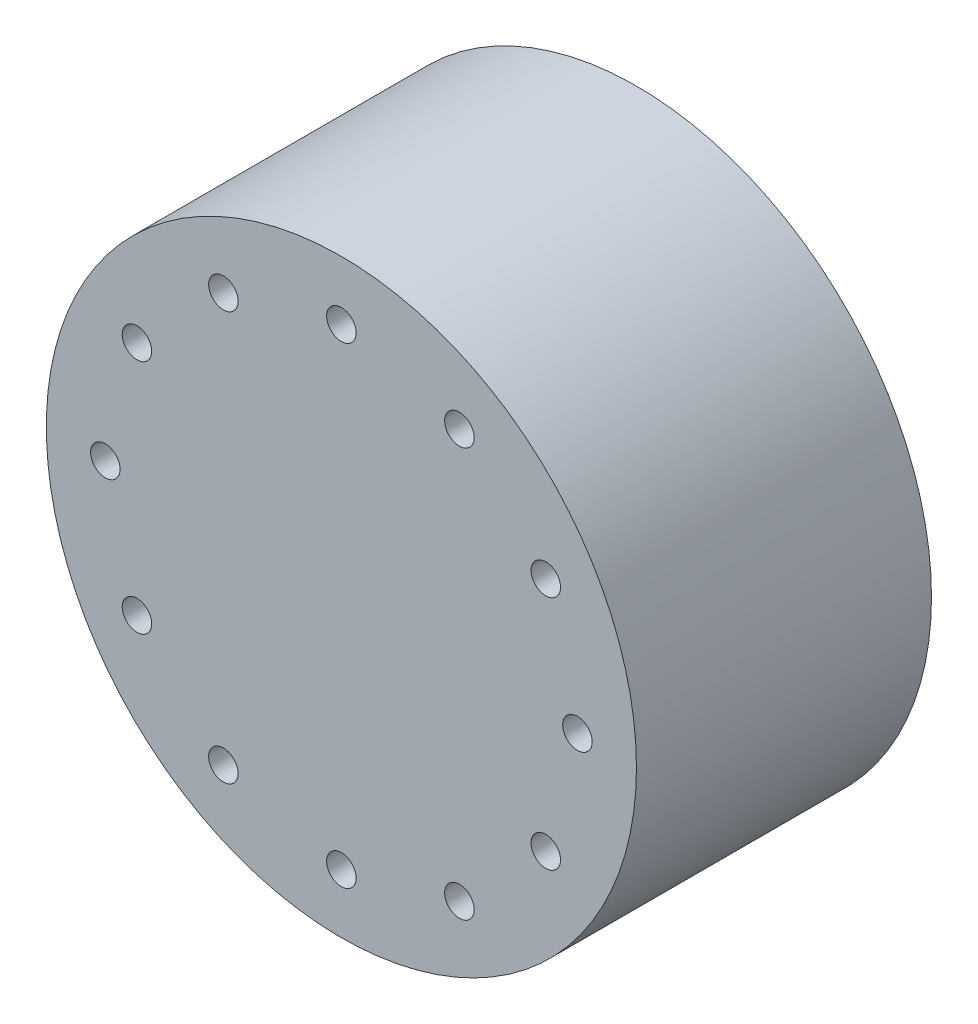
from build123d import *

# Parameters (mm, degrees)
SKETCH1_R           = 5
BOSS_EXTRUDE1_DEPTH = 5
SKETCH2_R           = 0.25
CUT_EXTRUDE1_DEPTH  = 6
CIRPATTERN1_COUNT   = 12


with BuildPart() as part:
    # Sketch1 → Boss-Extrude1 (new body)
    with BuildSketch(Plane.XY):
        Circle(SKETCH1_R)
    extrude(amount=BOSS_EXTRUDE1_DEPTH)

    # Sketch2 → Cut-Extrude1 (cut, through all)
    with BuildSketch(Plane.XY.offset(5)):
        with Locations((4, 0)):
            Circle(SKETCH2_R)
    cut_extrude1 = extrude(amount=-CUT_EXTRUDE1_DEPTH, mode=Mode.SUBTRACT)

    # CirPattern1: Cut-Extrude1 ×12 about axis
    cirpattern1_axis = Axis((0, 0, 0), (0, 0, 1))
    for i in range(1, CIRPATTERN1_COUNT):
        add(cut_extrude1.rotate(cirpattern1_axis, i * 360 / CIRPATTERN1_COUNT), mode=Mode.SUBTRACT)


solid = part.part
